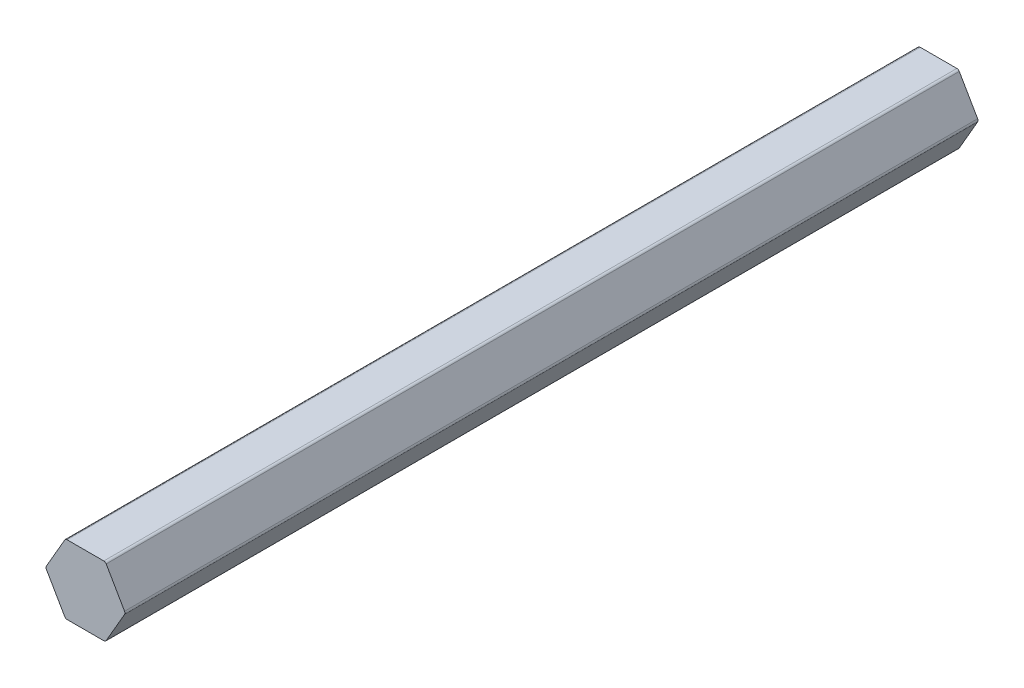
from build123d import *

# Parameters (mm, degrees)
BOSS_EXTRUDE1_DEPTH = 156.464


with BuildPart() as part:
    # Sketch1 → Boss-Extrude1 (new body)
    with BuildSketch(Plane(origin=(0, 0, -228.6), x_dir=(-1, 0, 0), z_dir=(0, 0, -1))):
        with BuildLine():
            Line((3.805488829, -6.0833), (7.171036753, -0.254))
            ThreePointArc((7.171036753, -0.254), (7.239095848, 0), (7.171036753, 0.254))
            Line((7.171036753, 0.254), (3.805488829, 6.0833))
            ThreePointArc((3.805488829, 6.0833), (3.619547924, 6.269240905), (3.365547924, 6.3373))
            Line((3.365547924, 6.3373), (-3.365547924, 6.3373))
            ThreePointArc((-3.365547924, 6.3373), (-3.619547924, 6.269240905), (-3.805488829, 6.0833))
            Line((-3.805488829, 6.0833), (-7.171036753, 0.254))
            ThreePointArc((-7.171036753, 0.254), (-7.239095848, 0), (-7.171036753, -0.254))
            Line((-7.171036753, -0.254), (-3.805488829, -6.0833))
            ThreePointArc((-3.805488829, -6.0833), (-3.619547924, -6.269240905), (-3.365547924, -6.3373))
            Line((-3.365547924, -6.3373), (3.365547924, -6.3373))
            ThreePointArc((3.365547924, -6.3373), (3.619547924, -6.269240905), (3.805488829, -6.0833))
        make_face()
    extrude(amount=-BOSS_EXTRUDE1_DEPTH)


solid = part.part
